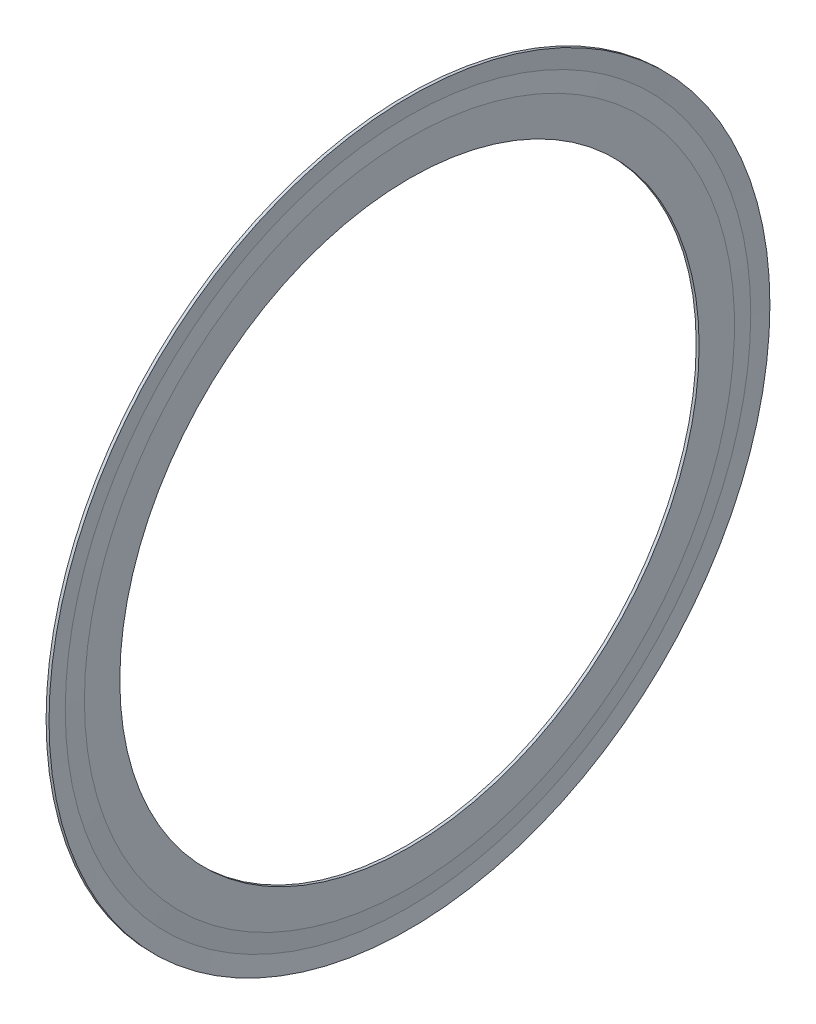
from build123d import *


with BuildPart() as part:
    # 草图1 → 旋转1 (revolve)
    with BuildSketch(Plane.XY):
        Polygon((4.55, 10.53125), (4.55, 9.9875), (4.64, 8.9), (4.73, 8.9), (4.73, 9.9875), (4.685, 10.53125), (4.73, 11.075), (4.64, 11.075), align=None)
    revolve(axis=Axis((50, 0, 0), (-1, 0, 0)))


solid = part.part
